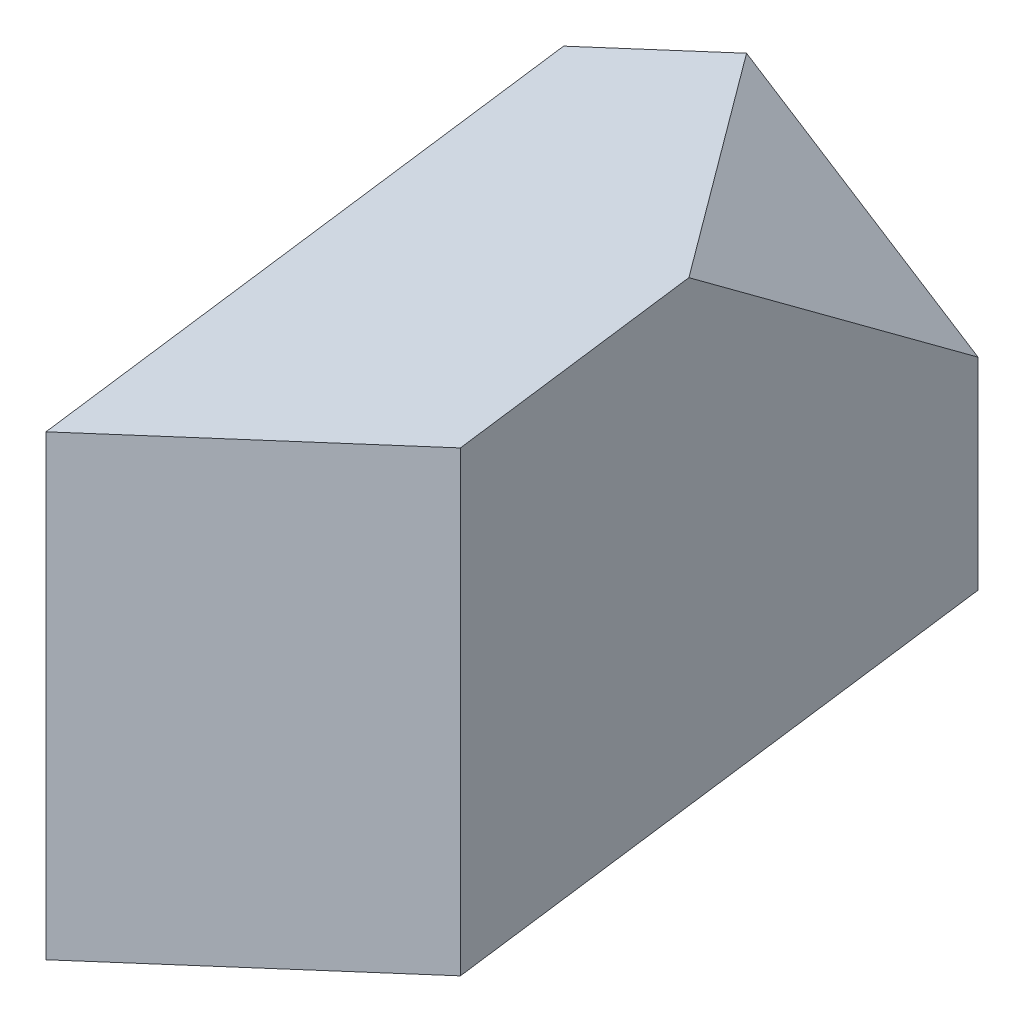
from build123d import *

# Parameters (mm, degrees)
SCHNITT_LINEAR_AUSTRAGEN1_DEPTH = 27.567610021


with BuildPart() as part:
    # Austragung1: sweep along a path in SK Pfad
    with BuildLine(Plane(origin=(0, 0, 0), x_dir=(0, 0, -1), z_dir=(0.843391446, -0.537299608, 0))) as austragung1_path:
        Line((0, 0), (50.603486749, 32.237976501))
    # SK Grundriss → Austragung1 (sweep)
    with BuildSketch(Plane.XY):
        Polygon((0, 0), (54.378467222, 25.357095704), (54.378467222, 85.357095704), (0, 60), align=None)
    sweep(path=austragung1_path.line)

    # Skizze2 → Schnitt-Linear austragen1 (cut, through all)
    with BuildSketch(Plane(origin=(58.655853729, 92.071247611, -39.620266542), x_dir=(0.863081214, -0.463933603, 0.199640751), z_dir=(0.505065162, 0.7927935, -0.341156339))):
        Polygon((15.113369899, 15.241721945), (-20.07640222, 7.593557233), (3.904191248, -17.963473004), align=None)
    extrude(amount=SCHNITT_LINEAR_AUSTRAGEN1_DEPTH, mode=Mode.SUBTRACT)


solid = part.part
